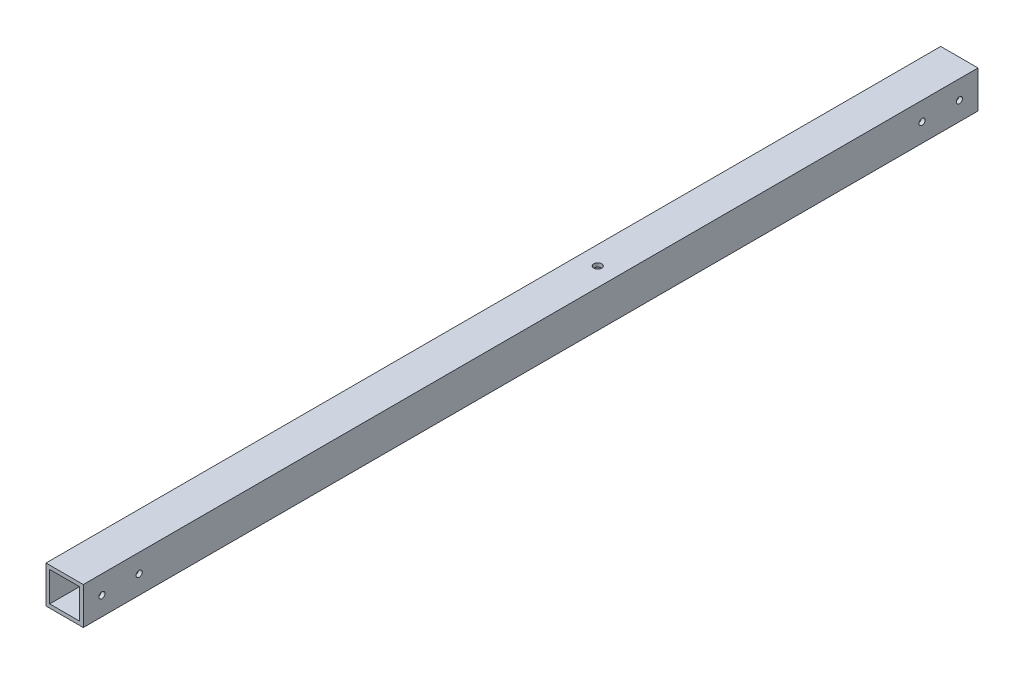
from build123d import *

# Parameters (mm, degrees)
SKETCH_1_W          = 20
SKETCH_1_H          = 20
SKETCH_1_W_2        = 16
SKETCH_1_H_2        = 16
EXTRUDE_1_DEPTH     = 560
SKETCH_3_R          = 2.2
CUT_EXTRUDE_2_DEPTH = 560
SKETCH_4_R          = 2.2
CUT_EXTRUDE_3_DEPTH = 560
SKETCH_5_W          = 35.553041162
SKETCH_5_H          = 54.410354854
CUT_EXTRUDE_4_DEPTH = 40
SKETCH_6_W          = 32.938502486
SKETCH_6_H          = 36.721798984
CUT_EXTRUDE_5_DEPTH = 40
SKETCH_8_R          = 1
CUT_EXTRUDE_7_DEPTH = 10
SKETCH_10_R         = 2.1
CUT_EXTRUDE_8_DEPTH = 21
SKETCH_11_R         = 6
CUT_EXTRUDE_9_DEPTH = 10
M4X0_7_1_D          = 3.3
M4X0_7_1_DEPTH      = 11.5
M4X0_7_1_TIP        = 0.991420021


with BuildPart() as part:
    # ｽｹｯﾁ1 → ﾎﾞｽ - 押し出し1 (new body)
    with BuildSketch(Plane.XY):
        Rectangle(SKETCH_1_W, SKETCH_1_H)
        Rectangle(SKETCH_1_W_2, SKETCH_1_H_2, mode=Mode.SUBTRACT)
    extrude(amount=EXTRUDE_1_DEPTH)

    # ｽｹｯﾁ3 → ｶｯﾄ - 押し出し2 (cut)
    with BuildSketch(Plane(origin=(10, 0, 0), x_dir=(0, 0, -1), z_dir=(1, 0, 0))):
        with Locations((-530, 0)):
            Circle(SKETCH_3_R)
        with Locations((-30, 0)):
            Circle(SKETCH_3_R)
    extrude(amount=-CUT_EXTRUDE_2_DEPTH, mode=Mode.SUBTRACT)

    # ｽｹｯﾁ4 → ｶｯﾄ - 押し出し3 (cut)
    with BuildSketch(Plane(origin=(0, 10, 0), x_dir=(1, 0, 0), z_dir=(0, 1, 0))):
        with Locations((0, -550)):
            Circle(SKETCH_4_R)
        with Locations((0, -10)):
            Circle(SKETCH_4_R)
    extrude(amount=-CUT_EXTRUDE_3_DEPTH, mode=Mode.SUBTRACT)

    # ｽｹｯﾁ5 → ｶｯﾄ - 押し出し4 (cut)
    with BuildSketch(Plane(origin=(0, 0, 0), x_dir=(-1, 0, 0), z_dir=(0, 0, -1))):
        Rectangle(SKETCH_5_W, SKETCH_5_H)
    extrude(amount=-CUT_EXTRUDE_4_DEPTH, mode=Mode.SUBTRACT)

    # ｽｹｯﾁ6 → ｶｯﾄ - 押し出し5 (cut)
    with BuildSketch(Plane.XY.offset(560)):
        Rectangle(SKETCH_6_W, SKETCH_6_H)
    extrude(amount=-CUT_EXTRUDE_5_DEPTH, mode=Mode.SUBTRACT)

    # ｽｹｯﾁ8 → ｶｯﾄ - 押し出し7 (cut)
    with BuildSketch(Plane(origin=(10, 0, 0), x_dir=(0, 0, -1), z_dir=(1, 0, 0))):
        with Locations((-50, 0)):
            Circle(SKETCH_8_R)
        with Locations((-70, 0)):
            Circle(SKETCH_8_R)
        with Locations((-490, 0)):
            Circle(SKETCH_8_R)
        with Locations((-510, 0)):
            Circle(SKETCH_8_R)
    extrude(amount=-CUT_EXTRUDE_7_DEPTH, mode=Mode.SUBTRACT)

    # ｽｹｯﾁ10 → ｶｯﾄ - 押し出し8 (cut, through all)
    with BuildSketch(Plane.XZ.offset(10)):
        with Locations((0, 234)):
            Circle(SKETCH_10_R)
    extrude(amount=-CUT_EXTRUDE_8_DEPTH, mode=Mode.SUBTRACT)

    # ｽｹｯﾁ11 → ｶｯﾄ - 押し出し9 (cut)
    with BuildSketch(Plane.XZ.offset(10)):
        with Locations((0, 234)):
            Circle(SKETCH_11_R)
    extrude(amount=-CUT_EXTRUDE_9_DEPTH, mode=Mode.SUBTRACT)

    # M4x0.7 ねじ穴1
    with Locations(Plane(origin=(10, 0, 50), x_dir=(0, 0, 1), z_dir=(1, 0, 0))):
        with Locations((0, 0), (20, 0), (440, 0), (460, 0)):
            Hole(M4X0_7_1_D / 2, depth=M4X0_7_1_DEPTH)
            with Locations((0, 0, -(M4X0_7_1_DEPTH + M4X0_7_1_TIP / 2))):  # 118° drill point
                Cone(0, M4X0_7_1_D / 2, M4X0_7_1_TIP, mode=Mode.SUBTRACT)


solid = part.part
